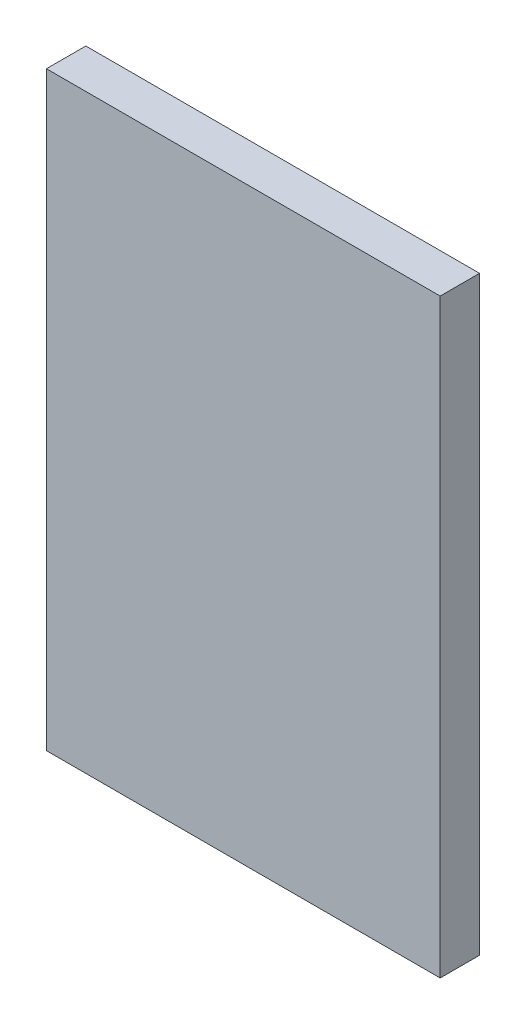
from build123d import *

# Parameters (mm, degrees)
SKETCH1_W           = 20
SKETCH1_H           = 30
BOSS_EXTRUDE1_DEPTH = 2


with BuildPart() as part:
    # Sketch1 → Boss-Extrude1 (new body)
    with BuildSketch(Plane.XY):
        with Locations((10, 15)):
            Rectangle(SKETCH1_W, SKETCH1_H)
    extrude(amount=BOSS_EXTRUDE1_DEPTH)


solid = part.part
